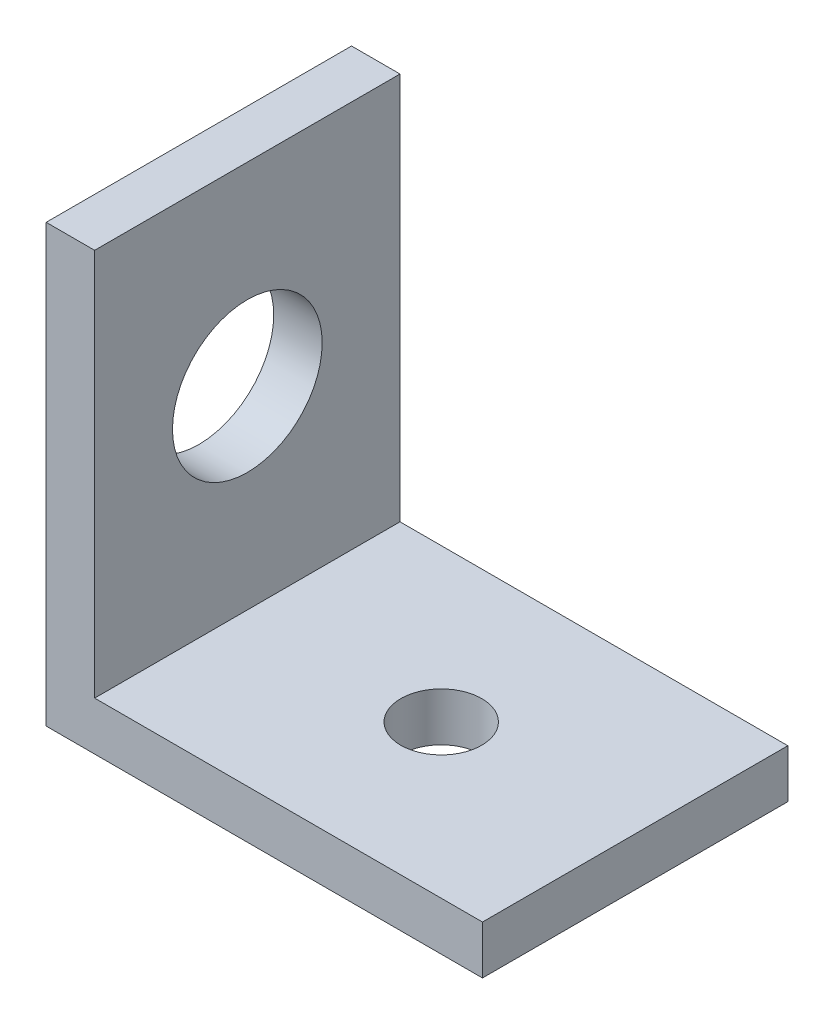
from build123d import *

# Parameters (mm, degrees)
BOSS_EXTRUDE1_DEPTH     = 20
F_3_8_CLEARANCE_HOLE1_D = 9.8044
M5_CLEARANCE_HOLE1_D    = 5.3
SKETCH2_R               = 9.525
CUT_EXTRUDE1_DEPTH      = 0.001


with BuildPart() as part:
    # Sketch1 → Boss-Extrude1 (new body)
    with BuildSketch(Plane.XY):
        Polygon((0, 2.54), (0, 25.4), (-3.175, 25.4), (-3.175, -3.175), (25.4, -3.175), (25.4, 0), (2.54, 0), (0, 0), align=None)
    extrude(amount=BOSS_EXTRUDE1_DEPTH)

    # 3/8 Clearance Hole1 (through all)
    with Locations(Plane.ZY.offset(3.175)):
        with Locations((10, 12.7)):
            Hole(F_3_8_CLEARANCE_HOLE1_D / 2)

    # M5 Clearance Hole1 (through all)
    with Locations(Plane(origin=(0, 0, 0), x_dir=(1, 0, 0), z_dir=(0, 1, 0))):
        with Locations((12.7, -10)):
            Hole(M5_CLEARANCE_HOLE1_D / 2)

    # Sketch2 → Cut-Extrude1 (cut)
    with BuildSketch(Plane.ZY.offset(3.175)):
        with Locations((10, 12.7)):
            Circle(SKETCH2_R)
    extrude(amount=-CUT_EXTRUDE1_DEPTH, mode=Mode.SUBTRACT)


solid = part.part
